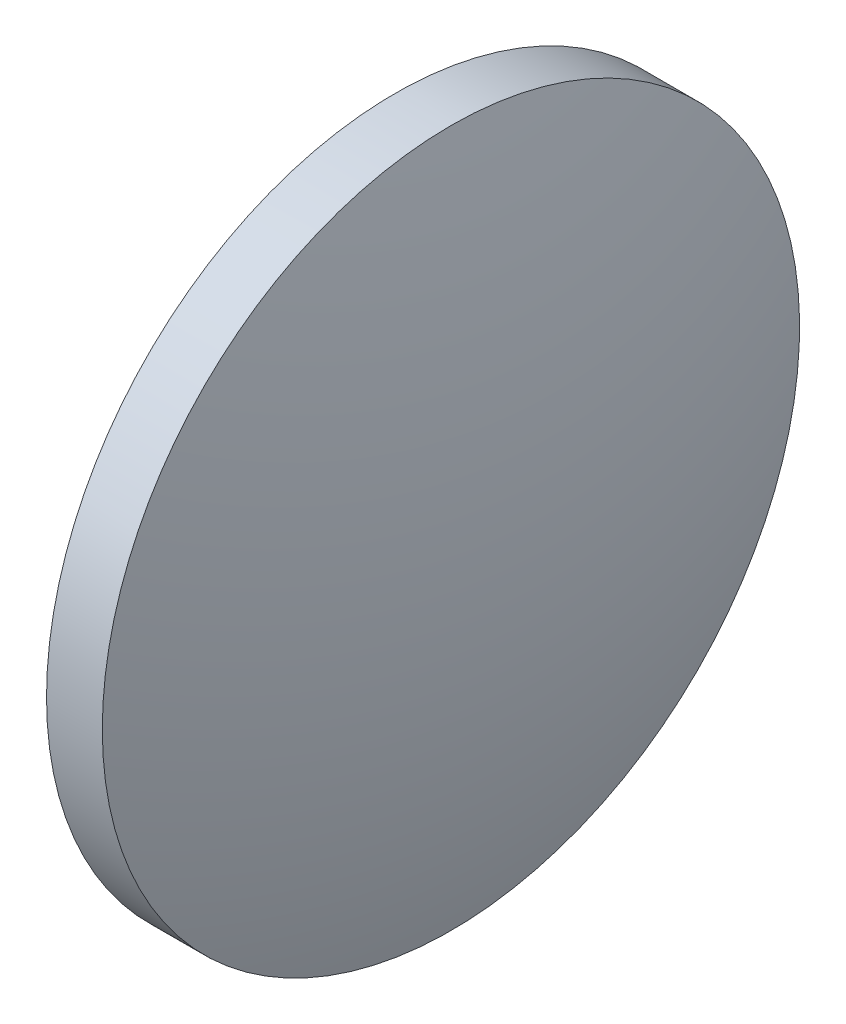
from build123d import *


with BuildPart() as part:
    # 草图1 → 旋转1 (revolve)
    with BuildSketch(Plane.XY):
        with BuildLine():
            Line((728.816807291, 258.855164799), (728.816807291, 271.355164799))
            Line((728.816807291, 271.355164799), (730.816807291, 271.355164799))
            ThreePointArc((730.816807291, 271.355164799), (732.268921391, 265.179988907), (732.756807291, 258.855164799))
            Line((732.756807291, 258.855164799), (728.816807291, 258.855164799))
        make_face()
    revolve(axis=Axis((724.074776049, 258.855164799, 0), (1, 0, 0)))


solid = part.part
